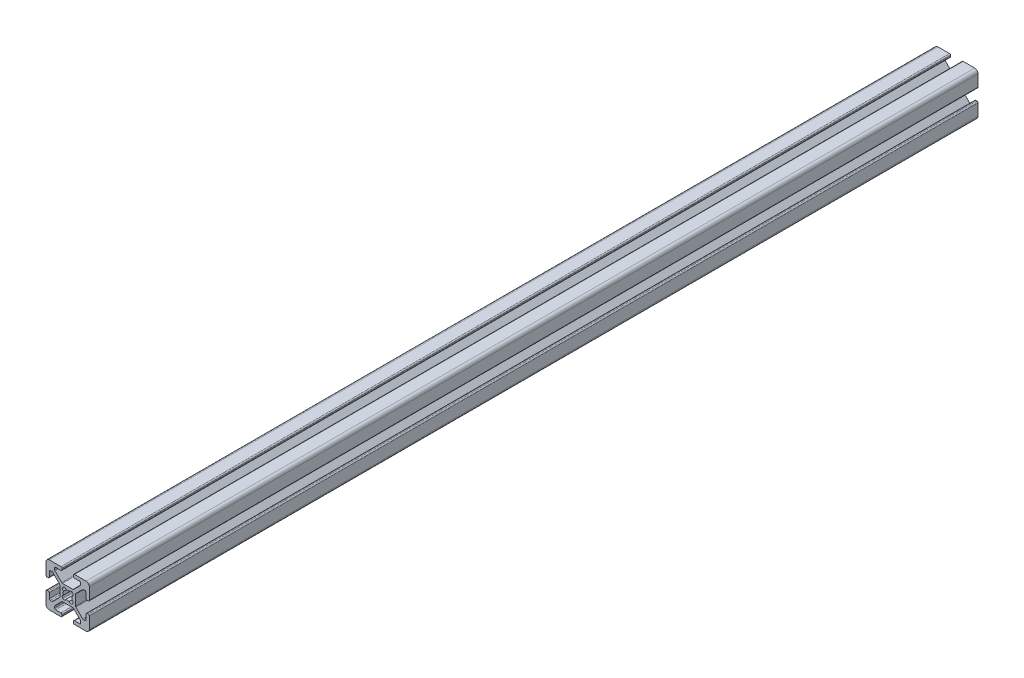
from build123d import *

# Parameters (mm, degrees)
EXTRUDE1_DEPTH = 410


with BuildPart() as part:
    # Sketch1 → Extrude1 (new body)
    with BuildSketch(Plane.XY):
        with BuildLine():
            Line((-5.032287798, -0.341059771), (-5.516287798, -0.341059771))
            ThreePointArc((-5.516287798, -0.341059771), (-5.875498042, -0.192270016), (-6.024287798, 0.166940229))
            Line((-6.024287798, 0.166940229), (-6.024287798, 2.515940229))
            ThreePointArc((-6.024287798, 2.515940229), (-6.173077553, 2.875150474), (-6.532287798, 3.023940229))
            Line((-6.532287798, 3.023940229), (-7.258207136, 3.023940229))
            ThreePointArc((-7.258207136, 3.023940229), (-7.45261032, 2.985271032), (-7.617417381, 2.875150474))
            Line((-7.617417381, 2.875150474), (-10.720498042, -0.227930187))
            ThreePointArc((-10.720498042, -0.227930187), (-10.8306186, -0.392737249), (-10.869287798, -0.587140432))
            Line((-10.869287798, -0.587140432), (-10.869287798, -5.354979109))
            ThreePointArc((-10.869287798, -5.354979109), (-10.8306186, -5.549382293), (-10.720498042, -5.714189354))
            Line((-10.720498042, -5.714189354), (-7.617417381, -8.817270016))
            ThreePointArc((-7.617417381, -8.817270016), (-7.45261032, -8.927390573), (-7.258207136, -8.966059771))
            Line((-7.258207136, -8.966059771), (-6.532287798, -8.966059771))
            ThreePointArc((-6.532287798, -8.966059771), (-6.173077553, -8.817270016), (-6.024287798, -8.458059771))
            Line((-6.024287798, -8.458059771), (-6.024287798, -6.109059771))
            ThreePointArc((-6.024287798, -6.109059771), (-5.875498042, -5.749849526), (-5.516287798, -5.601059771))
            Line((-5.516287798, -5.601059771), (-5.032287798, -5.601059771))
            ThreePointArc((-5.032287798, -5.601059771), (-4.673077553, -5.749849526), (-4.524287798, -6.109059771))
            Line((-4.524287798, -6.109059771), (-4.524287798, -11.471059771))
            ThreePointArc((-4.524287798, -11.471059771), (-4.963627626, -12.531719943), (-6.024287798, -12.971059771))
            Line((-6.024287798, -12.971059771), (-11.386287798, -12.971059771))
            ThreePointArc((-11.386287798, -12.971059771), (-11.745498042, -12.822270016), (-11.894287798, -12.463059771))
            Line((-11.894287798, -12.463059771), (-11.894287798, -11.979059771))
            ThreePointArc((-11.894287798, -11.979059771), (-11.745498042, -11.619849526), (-11.386287798, -11.471059771))
            Line((-11.386287798, -11.471059771), (-9.037287798, -11.471059771))
            ThreePointArc((-9.037287798, -11.471059771), (-8.678077553, -11.322270016), (-8.529287798, -10.963059771))
            Line((-8.529287798, -10.963059771), (-8.529287798, -10.237140432))
            ThreePointArc((-8.529287798, -10.237140432), (-8.567956995, -10.042737249), (-8.678077553, -9.877930187))
            Line((-8.678077553, -9.877930187), (-11.781158214, -6.774849526))
            ThreePointArc((-11.781158214, -6.774849526), (-11.945965275, -6.664728968), (-12.140368459, -6.626059771))
            Line((-12.140368459, -6.626059771), (-16.908207136, -6.626059771))
            ThreePointArc((-16.908207136, -6.626059771), (-17.10261032, -6.664728968), (-17.267417381, -6.774849526))
            Line((-17.267417381, -6.774849526), (-20.370498042, -9.877930187))
            ThreePointArc((-20.370498042, -9.877930187), (-20.4806186, -10.042737249), (-20.519287798, -10.237140432))
            Line((-20.519287798, -10.237140432), (-20.519287798, -10.963059771))
            ThreePointArc((-20.519287798, -10.963059771), (-20.370498042, -11.322270016), (-20.011287798, -11.471059771))
            Line((-20.011287798, -11.471059771), (-17.662287798, -11.471059771))
            ThreePointArc((-17.662287798, -11.471059771), (-17.303077553, -11.619849526), (-17.154287798, -11.979059771))
            Line((-17.154287798, -11.979059771), (-17.154287798, -12.463059771))
            ThreePointArc((-17.154287798, -12.463059771), (-17.303077553, -12.822270016), (-17.662287798, -12.971059771))
            Line((-17.662287798, -12.971059771), (-23.024287798, -12.971059771))
            ThreePointArc((-23.024287798, -12.971059771), (-24.084947969, -12.531719943), (-24.524287798, -11.471059771))
            Line((-24.524287798, -11.471059771), (-24.524287798, -6.109059771))
            ThreePointArc((-24.524287798, -6.109059771), (-24.375498042, -5.749849526), (-24.016287798, -5.601059771))
            Line((-24.016287798, -5.601059771), (-23.532287798, -5.601059771))
            ThreePointArc((-23.532287798, -5.601059771), (-23.173077553, -5.749849526), (-23.024287798, -6.109059771))
            Line((-23.024287798, -6.109059771), (-23.024287798, -8.458059771))
            ThreePointArc((-23.024287798, -8.458059771), (-22.875498042, -8.817270016), (-22.516287798, -8.966059771))
            Line((-22.516287798, -8.966059771), (-21.790368459, -8.966059771))
            ThreePointArc((-21.790368459, -8.966059771), (-21.595965275, -8.927390573), (-21.431158214, -8.817270016))
            Line((-21.431158214, -8.817270016), (-18.328077553, -5.714189354))
            ThreePointArc((-18.328077553, -5.714189354), (-18.217956995, -5.549382293), (-18.179287798, -5.354979109))
            Line((-18.179287798, -5.354979109), (-18.179287798, -0.587140432))
            ThreePointArc((-18.179287798, -0.587140432), (-18.217956995, -0.392737249), (-18.328077553, -0.227930187))
            Line((-18.328077553, -0.227930187), (-21.431158214, 2.875150474))
            ThreePointArc((-21.431158214, 2.875150474), (-21.595965275, 2.985271032), (-21.790368459, 3.023940229))
            Line((-21.790368459, 3.023940229), (-22.516287798, 3.023940229))
            ThreePointArc((-22.516287798, 3.023940229), (-22.875498042, 2.875150474), (-23.024287798, 2.515940229))
            Line((-23.024287798, 2.515940229), (-23.024287798, 0.166940229))
            ThreePointArc((-23.024287798, 0.166940229), (-23.173077553, -0.192270016), (-23.532287798, -0.341059771))
            Line((-23.532287798, -0.341059771), (-24.016287798, -0.341059771))
            ThreePointArc((-24.016287798, -0.341059771), (-24.375498042, -0.192270016), (-24.524287798, 0.166940229))
            Line((-24.524287798, 0.166940229), (-24.524287798, 5.528940229))
            ThreePointArc((-24.524287798, 5.528940229), (-24.084947969, 6.589600401), (-23.024287798, 7.028940229))
            Line((-23.024287798, 7.028940229), (-17.662287798, 7.028940229))
            ThreePointArc((-17.662287798, 7.028940229), (-17.303077553, 6.880150474), (-17.154287798, 6.520940229))
            Line((-17.154287798, 6.520940229), (-17.154287798, 6.036940229))
            ThreePointArc((-17.154287798, 6.036940229), (-17.303077553, 5.677729984), (-17.662287798, 5.528940229))
            Line((-17.662287798, 5.528940229), (-20.011287798, 5.528940229))
            ThreePointArc((-20.011287798, 5.528940229), (-20.370498042, 5.380150474), (-20.519287798, 5.020940229))
            Line((-20.519287798, 5.020940229), (-20.519287798, 4.295020891))
            ThreePointArc((-20.519287798, 4.295020891), (-20.4806186, 4.100617707), (-20.370498042, 3.935810646))
            Line((-20.370498042, 3.935810646), (-17.267417381, 0.832729984))
            ThreePointArc((-17.267417381, 0.832729984), (-17.10261032, 0.722609427), (-16.908207136, 0.683940229))
            Line((-16.908207136, 0.683940229), (-12.140368459, 0.683940229))
            ThreePointArc((-12.140368459, 0.683940229), (-11.945965275, 0.722609427), (-11.781158214, 0.832729984))
            Line((-11.781158214, 0.832729984), (-8.678077553, 3.935810646))
            ThreePointArc((-8.678077553, 3.935810646), (-8.567956995, 4.100617707), (-8.529287798, 4.295020891))
            Line((-8.529287798, 4.295020891), (-8.529287798, 5.020940229))
            ThreePointArc((-8.529287798, 5.020940229), (-8.678077553, 5.380150474), (-9.037287798, 5.528940229))
            Line((-9.037287798, 5.528940229), (-11.386287798, 5.528940229))
            ThreePointArc((-11.386287798, 5.528940229), (-11.745498042, 5.677729984), (-11.894287798, 6.036940229))
            Line((-11.894287798, 6.036940229), (-11.894287798, 6.520940229))
            ThreePointArc((-11.894287798, 6.520940229), (-11.745498042, 6.880150474), (-11.386287798, 7.028940229))
            Line((-11.386287798, 7.028940229), (-6.024287798, 7.028940229))
            ThreePointArc((-6.024287798, 7.028940229), (-4.963627626, 6.589600401), (-4.524287798, 5.528940229))
            Line((-4.524287798, 5.528940229), (-4.524287798, 0.166940229))
            ThreePointArc((-4.524287798, 0.166940229), (-4.673077553, -0.192270016), (-5.032287798, -0.341059771))
        make_face()
        with BuildLine():
            Line((-12.399386954, -5.275565737), (-12.219781831, -5.095960615))
            ThreePointArc((-12.219781831, -5.095960615), (-12.018349781, -4.327527582), (-12.589154291, -3.775036489))
            ThreePointArc((-12.589154291, -3.775036489), (-12.428787798, -2.971059771), (-12.589154291, -2.167083053))
            ThreePointArc((-12.589154291, -2.167083053), (-12.018349781, -1.61459196), (-12.219781831, -0.846158927))
            Line((-12.219781831, -0.846158927), (-12.399386954, -0.666553805))
            ThreePointArc((-12.399386954, -0.666553805), (-13.167819987, -0.465121754), (-13.72031108, -1.035926265))
            ThreePointArc((-13.72031108, -1.035926265), (-14.524287798, -0.875559771), (-15.328264516, -1.035926265))
            ThreePointArc((-15.328264516, -1.035926265), (-15.880755608, -0.465121754), (-16.649188641, -0.666553805))
            Line((-16.649188641, -0.666553805), (-16.828793764, -0.846158927))
            ThreePointArc((-16.828793764, -0.846158927), (-17.030225814, -1.61459196), (-16.459421304, -2.167083053))
            ThreePointArc((-16.459421304, -2.167083053), (-16.619787798, -2.971059771), (-16.459421304, -3.775036489))
            ThreePointArc((-16.459421304, -3.775036489), (-17.030225814, -4.327527582), (-16.828793764, -5.095960615))
            Line((-16.828793764, -5.095960615), (-16.649188641, -5.275565737))
            ThreePointArc((-16.649188641, -5.275565737), (-15.880755608, -5.476997788), (-15.328264516, -4.906193277))
            ThreePointArc((-15.328264516, -4.906193277), (-14.524287798, -5.066559771), (-13.72031108, -4.906193277))
            ThreePointArc((-13.72031108, -4.906193277), (-13.167819987, -5.476997788), (-12.399386954, -5.275565737))
        make_face(mode=Mode.SUBTRACT)
    extrude(amount=EXTRUDE1_DEPTH)


solid = part.part
